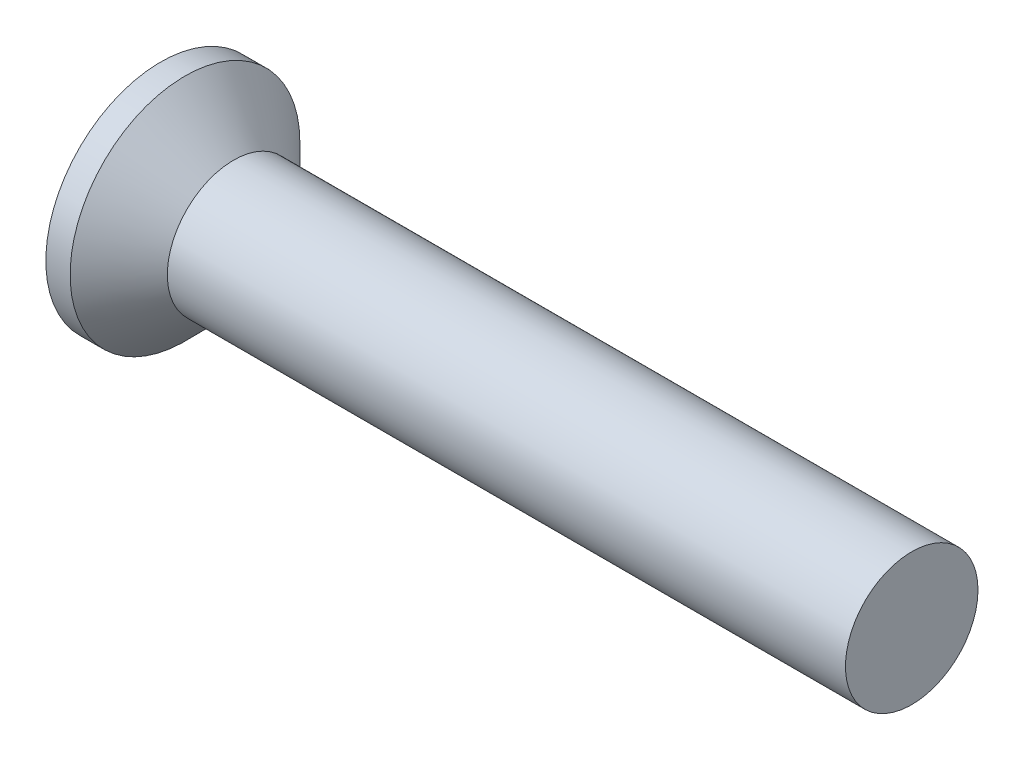
from build123d import *

# Parameters (mm, degrees)
CROSSRECESS_DEPTH = 0.825
DRAFT9_ANGLE      = 30
FILLET5_R         = 0.3


with BuildPart() as part:
    # Sketch1 → Base (revolve)
    with BuildSketch(Plane.XY):
        Polygon((17, 1.5), (2.65, 1.5), (1.65, 1.5), (0.55, 2.6), (0, 2.6), (0, 0), (17, 0), align=None)
    revolve(axis=Axis((4.515812911, 0, 0), (-1, 0, 0)))

    # Sketch6 → CrossRecess (cut)
    with BuildSketch(Plane(origin=(0, 0, 0), x_dir=(0, 0, -1), z_dir=(1, 0, 0))):
        Polygon((0.32, 0.32), (0.32, 1.6), (-0.32, 1.6), (-0.32, 0.32), (-1.6, 0.32), (-1.6, -0.32), (-0.32, -0.32), (-0.32, -1.6), (0.32, -1.6), (0.32, -0.32), (1.6, -0.32), (1.6, 0.32), align=None)
    extrude(amount=CROSSRECESS_DEPTH, mode=Mode.SUBTRACT)

    # Draft9
    draft9_faces = [part.faces().sort_by_distance(p)[0] for p in [
        (0.4125, 1.6, 0),
        (0.4125, 0, 1.6),
        (0.4125, -1.6, 0),
        (0.4125, 0, -1.6),
    ]]
    draft(draft9_faces, Plane(origin=(0, 2.6, 0), x_dir=(0, 0, -1), z_dir=(-1, 0, 0)), DRAFT9_ANGLE)

    # Fillet5
    fillet5_edges = [part.edges().sort_by_distance(p)[0] for p in [
        (0.4125, 0.32, 0.32),
        (0.4125, -0.32, 0.32),
        (0.4125, -0.32, -0.32),
        (0.4125, 0.32, -0.32),
    ]]
    fillet(fillet5_edges, radius=FILLET5_R)


solid = part.part
